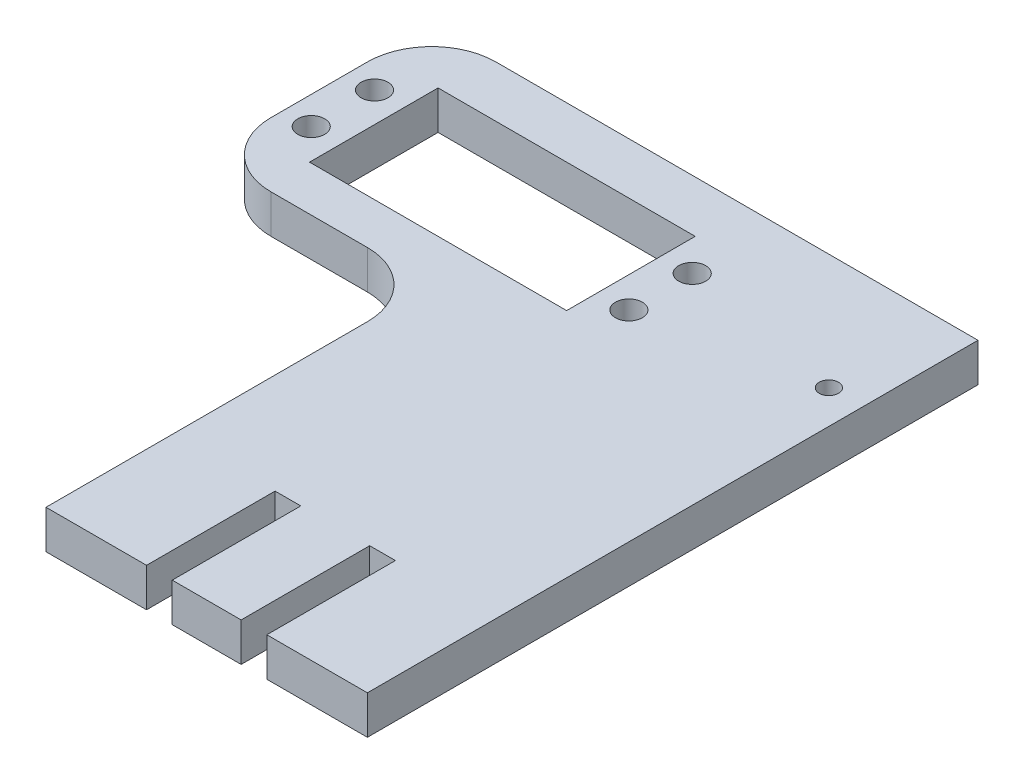
from build123d import *

# Parameters (mm, degrees)
SKETCH1_W           = 35
SKETCH1_H           = 35
SKETCH1_W_2         = 50
SKETCH1_H_2         = 95
BOSS_EXTRUDE1_DEPTH = 6
FILLET1_R           = 10
SKETCH2_W           = 4
SKETCH2_H           = 20
CUT_EXTRUDE1_DEPTH  = 10
SKETCH3_W           = 40
SKETCH3_H           = 20
CUT_EXTRUDE2_DEPTH  = 7
SKETCH4_R           = 1.5
CUT_EXTRUDE3_DEPTH  = 7
SKETCH5_R           = 2.1
CUT_EXTRUDE4_DEPTH  = 7


with BuildPart() as part:
    # Sketch1 → Boss-Extrude1 (new body)
    with BuildSketch(Plane(origin=(0, 0, 0), x_dir=(1, 0, 0), z_dir=(0, 1, 0))):
        with Locations((-42.5, 30)):
            Rectangle(SKETCH1_W, SKETCH1_H)
        Rectangle(SKETCH1_W_2, SKETCH1_H_2)
    extrude(amount=BOSS_EXTRUDE1_DEPTH)

    # Fillet1
    fillet1_edges = [part.edges().sort_by_distance(p)[0] for p in [
        (-60, 3, -47.5),
        (-25, 3, -12.5),
        (-60, 3, -12.5),
    ]]
    fillet(fillet1_edges, radius=FILLET1_R)

    # Sketch2 → Cut-Extrude1 (cut)
    with BuildSketch(Plane(origin=(0, 6, 0), x_dir=(1, 0, 0), z_dir=(0, 1, 0))):
        with Locations((-7.36, -37.5)):
            Rectangle(SKETCH2_W, SKETCH2_H)
        with Locations((7.36, -37.5)):
            Rectangle(SKETCH2_W, SKETCH2_H)
    extrude(amount=-CUT_EXTRUDE1_DEPTH, mode=Mode.SUBTRACT)

    # Sketch3 → Cut-Extrude2 (cut, through all)
    with BuildSketch(Plane(origin=(0, 6, 0), x_dir=(1, 0, 0), z_dir=(0, 1, 0))):
        with Locations((-31, 29.5)):
            Rectangle(SKETCH3_W, SKETCH3_H)
    extrude(amount=-CUT_EXTRUDE2_DEPTH, mode=Mode.SUBTRACT)

    # Sketch4 → Cut-Extrude3 (cut, through all)
    with BuildSketch(Plane(origin=(0, 0, 0), x_dir=(-1, 0, 0), z_dir=(0, -1, 0))):
        with Locations((-19.8, 29.5)):
            Circle(SKETCH4_R)
    extrude(amount=-CUT_EXTRUDE3_DEPTH, mode=Mode.SUBTRACT)

    # Sketch5 → Cut-Extrude4 (cut, through all)
    with BuildSketch(Plane(origin=(0, 6, 0), x_dir=(1, 0, 0), z_dir=(0, 1, 0))):
        with Locations((-55.661145618, 24.425)):
            Circle(SKETCH5_R)
        with Locations((-55.661145618, 34.275)):
            Circle(SKETCH5_R)
        with Locations((-6.238854382, 34.275)):
            Circle(SKETCH5_R)
        with Locations((-6.238854382, 24.425)):
            Circle(SKETCH5_R)
    extrude(amount=-CUT_EXTRUDE4_DEPTH, mode=Mode.SUBTRACT)


solid = part.part
